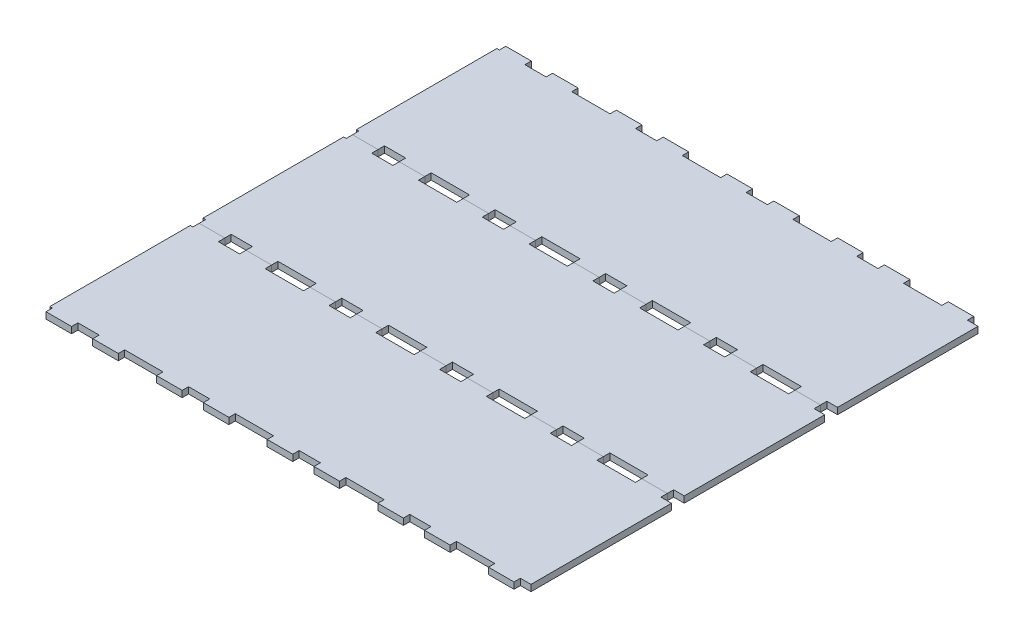
from build123d import *

# Parameters (mm, degrees)
SKETCH1_W                 = 516.930563546
SKETCH1_H                 = 152.4
BOSS_EXTRUDE1_DEPTH       = 6.35
SKETCH2_W                 = 21.085226308
SKETCH2_H                 = 6.35
SKETCH2_W_2               = 19.05
CUT_EXTRUDE1_DEPTH        = 7.35
LPATTERN1_COUNT           = 3
LPATTERN1_PITCH           = 109.985226308
LPATTERN1_COL_COUNT       = 3
LPATTERN1_COL_PITCH       = 109.985226308
MIRROR1_COPY_1_SKETCH_W   = 21.085226308
MIRROR1_COPY_1_SKETCH_H   = 6.35
MIRROR1_COPY_1_SKETCH_W_2 = 19.05
MIRROR1_COPY_1_DEPTH      = 7.35
MIRROR1_COPY_2_SKETCH_W   = 21.085226308
MIRROR1_COPY_2_SKETCH_H   = 6.35
MIRROR1_COPY_2_SKETCH_W_2 = 19.05
MIRROR1_COPY_2_DEPTH      = 7.35
MIRROR1_COPY_3_SKETCH_W   = 21.085226308
MIRROR1_COPY_3_SKETCH_H   = 6.35
MIRROR1_COPY_3_SKETCH_W_2 = 19.05
MIRROR1_COPY_3_DEPTH      = 7.35
MIRROR1_COPY_4_SKETCH_W   = 21.085226308
MIRROR1_COPY_4_SKETCH_H   = 6.35
MIRROR1_COPY_4_SKETCH_W_2 = 19.05
MIRROR1_COPY_4_DEPTH      = 7.35
CUT_EXTRUDE2_DEPTH        = 7.35
LPATTERN2_COUNT           = 3
LPATTERN2_PITCH           = 152.4


with BuildPart() as part:
    # Sketch1 → Boss-Extrude1 (new body)
    with BuildSketch(Plane(origin=(0, 0, 0), x_dir=(1, 0, 0), z_dir=(0, 1, 0))):
        Rectangle(SKETCH1_W, SKETCH1_H)
    extrude(amount=BOSS_EXTRUDE1_DEPTH)

    # Sketch2 → Cut-Extrude1 (cut, through all)
    with BuildSketch(Plane(origin=(0, 6.35, 0), x_dir=(1, 0, 0), z_dir=(0, 1, 0))):
        with Locations((0, -73.025)):
            Rectangle(SKETCH2_W, SKETCH2_H)
        with Locations((-45.467613154, -73.025)):
            Rectangle(SKETCH2_W_2, SKETCH2_H)
        with Locations((45.467613154, -73.025)):
            Rectangle(SKETCH2_W_2, SKETCH2_H)
    cut_extrude1 = extrude(amount=-CUT_EXTRUDE1_DEPTH, mode=Mode.SUBTRACT)

    # LPattern1: Cut-Extrude1 ×3
    with Locations(*[(i * LPATTERN1_PITCH, 0, 0) for i in range(1, LPATTERN1_COUNT)]):
        add(cut_extrude1, mode=Mode.SUBTRACT)

    # LPattern1 col: Cut-Extrude1 ×3
    with Locations(*[(-i * LPATTERN1_COL_PITCH, 0, 0) for i in range(1, LPATTERN1_COL_COUNT)]):
        add(cut_extrude1, mode=Mode.SUBTRACT)

    # Mirror1: Cut-Extrude1 across plane
    add(cut_extrude1.mirror(Plane.XY), mode=Mode.SUBTRACT)

    # Mirror1 copy 1 sketch → Mirror1 copy 1 (cut, through all)
    with BuildSketch(Plane(origin=(109.985226308, 6.35, 0), x_dir=(1, 0, 0), z_dir=(0, 1, 0))):
        with Locations((0, 73.025)):
            Rectangle(MIRROR1_COPY_1_SKETCH_W, MIRROR1_COPY_1_SKETCH_H)
        with Locations((-45.467613154, 73.025)):
            Rectangle(MIRROR1_COPY_1_SKETCH_W_2, MIRROR1_COPY_1_SKETCH_H)
        with Locations((45.467613154, 73.025)):
            Rectangle(MIRROR1_COPY_1_SKETCH_W_2, MIRROR1_COPY_1_SKETCH_H)
    extrude(amount=-MIRROR1_COPY_1_DEPTH, mode=Mode.SUBTRACT)

    # Mirror1 copy 2 sketch → Mirror1 copy 2 (cut, through all)
    with BuildSketch(Plane(origin=(219.970452616, 6.35, 0), x_dir=(1, 0, 0), z_dir=(0, 1, 0))):
        with Locations((0, 73.025)):
            Rectangle(MIRROR1_COPY_2_SKETCH_W, MIRROR1_COPY_2_SKETCH_H)
        with Locations((-45.467613154, 73.025)):
            Rectangle(MIRROR1_COPY_2_SKETCH_W_2, MIRROR1_COPY_2_SKETCH_H)
        with Locations((45.467613154, 73.025)):
            Rectangle(MIRROR1_COPY_2_SKETCH_W_2, MIRROR1_COPY_2_SKETCH_H)
    extrude(amount=-MIRROR1_COPY_2_DEPTH, mode=Mode.SUBTRACT)

    # Mirror1 copy 3 sketch → Mirror1 copy 3 (cut, through all)
    with BuildSketch(Plane(origin=(-109.985226308, 6.35, 0), x_dir=(1, 0, 0), z_dir=(0, 1, 0))):
        with Locations((0, 73.025)):
            Rectangle(MIRROR1_COPY_3_SKETCH_W, MIRROR1_COPY_3_SKETCH_H)
        with Locations((-45.467613154, 73.025)):
            Rectangle(MIRROR1_COPY_3_SKETCH_W_2, MIRROR1_COPY_3_SKETCH_H)
        with Locations((45.467613154, 73.025)):
            Rectangle(MIRROR1_COPY_3_SKETCH_W_2, MIRROR1_COPY_3_SKETCH_H)
    extrude(amount=-MIRROR1_COPY_3_DEPTH, mode=Mode.SUBTRACT)

    # Mirror1 copy 4 sketch → Mirror1 copy 4 (cut, through all)
    with BuildSketch(Plane(origin=(-219.970452616, 6.35, 0), x_dir=(1, 0, 0), z_dir=(0, 1, 0))):
        with Locations((0, 73.025)):
            Rectangle(MIRROR1_COPY_4_SKETCH_W, MIRROR1_COPY_4_SKETCH_H)
        with Locations((-45.467613154, 73.025)):
            Rectangle(MIRROR1_COPY_4_SKETCH_W_2, MIRROR1_COPY_4_SKETCH_H)
        with Locations((45.467613154, 73.025)):
            Rectangle(MIRROR1_COPY_4_SKETCH_W_2, MIRROR1_COPY_4_SKETCH_H)
    extrude(amount=-MIRROR1_COPY_4_DEPTH, mode=Mode.SUBTRACT)

    # Sketch3 → Cut-Extrude2 (cut, through all)
    with BuildSketch(Plane(origin=(0, 6.35, 0), x_dir=(1, 0, 0), z_dir=(0, 1, 0))):
        Polygon((219.970452616, 69.85), (219.970452616, -76.2), (258.465281773, -76.2), (258.465281773, 76.2), (219.970452616, 76.2), align=None)
    extrude(amount=-CUT_EXTRUDE2_DEPTH, mode=Mode.SUBTRACT)


with BuildPart() as lpattern2_1:
    # LPattern2: pattern copy
    add(part.part.moved(Location(Vector(0, 0, 1) * (1 * LPATTERN2_PITCH))))


with BuildPart() as lpattern2_2:
    # LPattern2: pattern copy
    add(part.part.moved(Location(Vector(0, 0, 1) * (2 * LPATTERN2_PITCH))))


solid = Compound([part.part, lpattern2_1.part, lpattern2_2.part])
